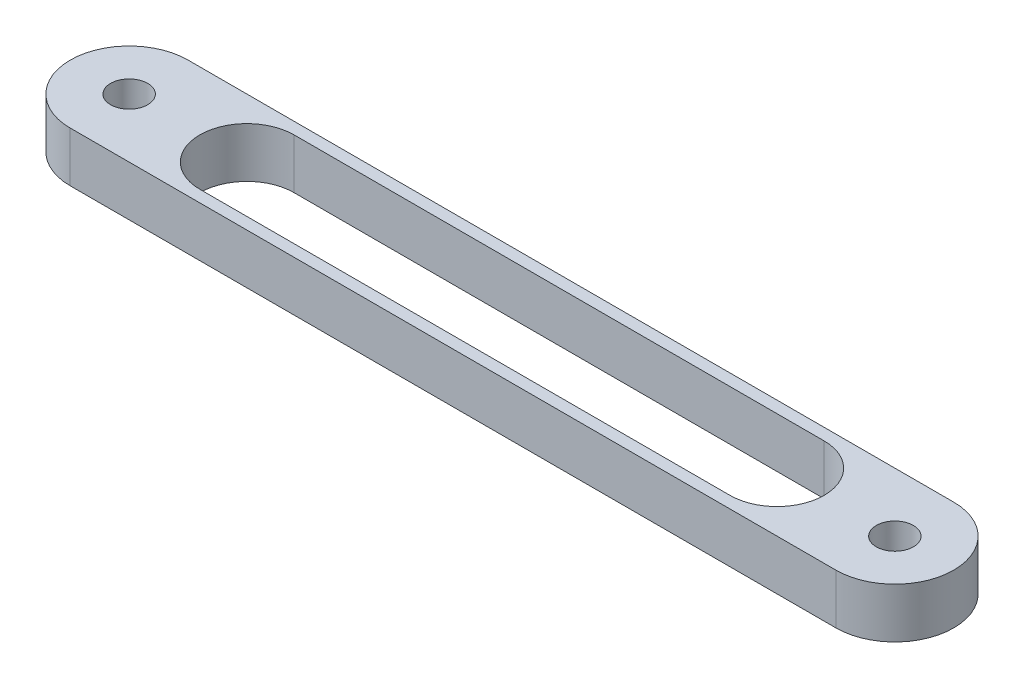
from build123d import *

# Parameters (mm, degrees)
BOSS_EXTRU_1_DEPTH      = 4.25
ESQUISSE2_R             = 3.15
ENL_V_MAT_EXTRU_1_DEPTH = 9.5


with BuildPart() as part:
    # Esquisse1 → Boss.-Extru.1 (new body, symmetric)
    with BuildSketch(Plane(origin=(0, 0, 0), x_dir=(1, 0, 0), z_dir=(0, 1, 0))):
        with BuildLine():
            Line((0, 10), (130, 10))
            ThreePointArc((130, 10), (140, 0), (130, -10))
            Line((130, -10), (0, -10))
            ThreePointArc((0, -10), (-10, 0), (0, 10))
        make_face()
        with BuildLine():
            Line((20, 8), (110, 8))
            ThreePointArc((110, 8), (118, 0), (110, -8))
            Line((110, -8), (20, -8))
            ThreePointArc((20, -8), (12, 0), (20, 8))
        make_face(mode=Mode.SUBTRACT)
    extrude(amount=BOSS_EXTRU_1_DEPTH, both=True)

    # Esquisse2 → Enlèv. mat.-Extru.1 (cut, through all)
    with BuildSketch(Plane(origin=(0, 4.25, 0), x_dir=(1, 0, 0), z_dir=(0, 1, 0))):
        Circle(ESQUISSE2_R)
        with Locations((130, 0)):
            Circle(ESQUISSE2_R)
    extrude(amount=-ENL_V_MAT_EXTRU_1_DEPTH, mode=Mode.SUBTRACT)


solid = part.part
